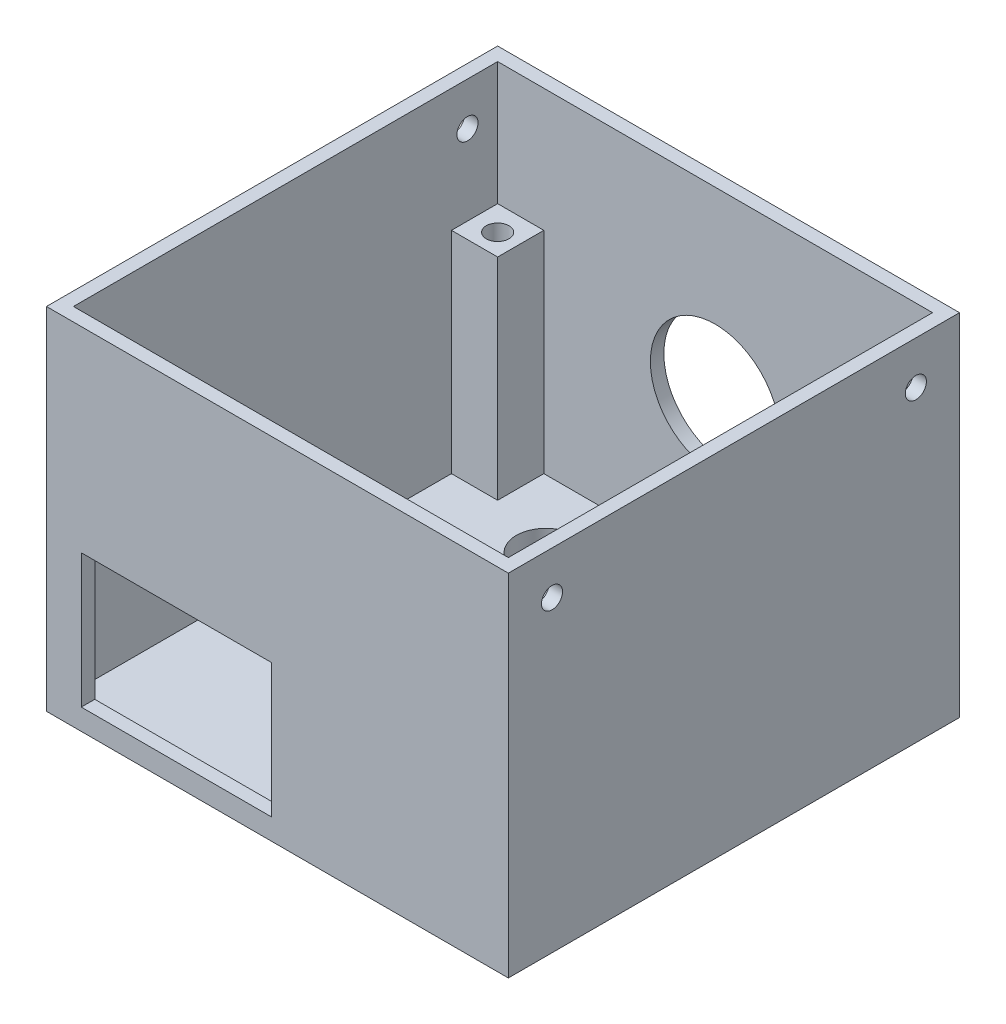
from build123d import *

# Parameters (mm, degrees)
SKETCH1_W           = 54.8
SKETCH1_H           = 53.53
BOSS_EXTRUDE1_DEPTH = 41.6
SKETCH2_W           = 51.6
SKETCH2_H           = 50.33
CUT_EXTRUDE1_DEPTH  = 39.6
SKETCH3_W           = 5.48
SKETCH3_H           = 5.48
BOSS_EXTRUDE2_DEPTH = 25
SKETCH4_R           = 1.35
CUT_EXTRUDE2_DEPTH  = 10
CUT_EXTRUDE3_REACH  = 43.6
SKETCH5_R           = 3.5
CUT_EXTRUDE4_REACH  = 43.6
SKETCH6_R           = 3.1
CUT_EXTRUDE5_REACH  = 43.6
SKETCH7_R           = 3.6
CUT_EXTRUDE6_REACH  = 56.8
SKETCH8_R           = 1.25
CUT_EXTRUDE7_REACH  = 56.8
SKETCH10_R          = 1.25
CUT_EXTRUDE8_REACH  = 55.53
SKETCH12_R          = 7.680495542
CUT_EXTRUDE9_REACH  = 55.53
SKETCH13_W          = 22.581735489
SKETCH13_H          = 15.862362247
CUT_EXTRUDE10_REACH = 56.8
SKETCH14_R          = 1.25


with BuildPart() as part:
    # Sketch1 → Boss-Extrude1 (new body)
    with BuildSketch(Plane(origin=(0, 0, 0), x_dir=(1, 0, 0), z_dir=(0, 1, 0))):
        Rectangle(SKETCH1_W, SKETCH1_H)
    extrude(amount=BOSS_EXTRUDE1_DEPTH)

    # Sketch2 → Cut-Extrude1 (cut)
    with BuildSketch(Plane(origin=(0, 41.6, 0), x_dir=(1, 0, 0), z_dir=(0, 1, 0))):
        Rectangle(SKETCH2_W, SKETCH2_H)
    extrude(amount=-CUT_EXTRUDE1_DEPTH, mode=Mode.SUBTRACT)

    # Sketch3 → Boss-Extrude2 (add)
    with BuildSketch(Plane(origin=(0, 2, 0), x_dir=(1, 0, 0), z_dir=(0, 1, 0))):
        with Locations((-23.06, 22.425)):
            Rectangle(SKETCH3_W, SKETCH3_H)
        with Locations((23.06, 22.425)):
            Rectangle(SKETCH3_W, SKETCH3_H)
        with Locations((23.06, -22.425)):
            Rectangle(SKETCH3_W, SKETCH3_H)
    extrude(amount=BOSS_EXTRUDE2_DEPTH)

    # Sketch4 → Cut-Extrude2 (cut)
    with BuildSketch(Plane(origin=(0, 27, 0), x_dir=(1, 0, 0), z_dir=(0, 1, 0))):
        with Locations((-22.86, 22.225)):
            Circle(SKETCH4_R)
        with Locations((22.86, 22.225)):
            Circle(SKETCH4_R)
        with Locations((22.86, -22.217113742)):
            Circle(SKETCH4_R)
    extrude(amount=-CUT_EXTRUDE2_DEPTH, mode=Mode.SUBTRACT)

    # Sketch5 → Cut-Extrude3 (cut, up to next)
    with BuildSketch(Plane(origin=(0, 0, 0), x_dir=(-1, 0, 0), z_dir=(0, -1, 0)), mode=Mode.PRIVATE) as cut_extrude3_sk1:
        with Locations((-12.762863618, 17.186859774)):
            Circle(SKETCH5_R)
    cut_extrude3_tool1 = extrude(cut_extrude3_sk1.sketch, amount=-CUT_EXTRUDE3_REACH, mode=Mode.PRIVATE) & part.part
    add(cut_extrude3_tool1.solids().sort_by_distance((12.762864, 0, -17.18686))[0], mode=Mode.SUBTRACT)
    # Sketch5 → Cut-Extrude3 (cut, up to next)
    with BuildSketch(Plane(origin=(0, 0, 0), x_dir=(-1, 0, 0), z_dir=(0, -1, 0)), mode=Mode.PRIVATE) as cut_extrude3_sk2:
        with Locations((12.108357792, 17.186859774)):
            Circle(SKETCH5_R)
    cut_extrude3_tool2 = extrude(cut_extrude3_sk2.sketch, amount=-CUT_EXTRUDE3_REACH, mode=Mode.PRIVATE) & part.part
    add(cut_extrude3_tool2.solids().sort_by_distance((-12.108358, 0, -17.18686))[0], mode=Mode.SUBTRACT)

    # Sketch6 → Cut-Extrude4 (cut, up to next)
    with BuildSketch(Plane(origin=(0, 0, 0), x_dir=(-1, 0, 0), z_dir=(0, -1, 0)), mode=Mode.PRIVATE) as cut_extrude4_sk1:
        with Locations((-16.908067186, 1.527180262)):
            Circle(SKETCH6_R)
    cut_extrude4_tool1 = extrude(cut_extrude4_sk1.sketch, amount=-CUT_EXTRUDE4_REACH, mode=Mode.PRIVATE) & part.part
    add(cut_extrude4_tool1.solids().sort_by_distance((16.908067, 0, -1.52718))[0], mode=Mode.SUBTRACT)
    # Sketch6 → Cut-Extrude4 (cut, up to next)
    with BuildSketch(Plane(origin=(0, 0, 0), x_dir=(-1, 0, 0), z_dir=(0, -1, 0)), mode=Mode.PRIVATE) as cut_extrude4_sk2:
        with Locations((-8.726744354, 1.527180262)):
            Circle(SKETCH6_R)
    cut_extrude4_tool2 = extrude(cut_extrude4_sk2.sketch, amount=-CUT_EXTRUDE4_REACH, mode=Mode.PRIVATE) & part.part
    add(cut_extrude4_tool2.solids().sort_by_distance((8.726744, 0, -1.52718))[0], mode=Mode.SUBTRACT)

    # Sketch7 → Cut-Extrude5 (cut, up to next)
    with BuildSketch(Plane(origin=(0, 0, 0), x_dir=(-1, 0, 0), z_dir=(0, -1, 0)), mode=Mode.PRIVATE) as cut_extrude5_sk1:
        with Locations((-12.653779314, -10.035756007)):
            Circle(SKETCH7_R)
    cut_extrude5_tool1 = extrude(cut_extrude5_sk1.sketch, amount=-CUT_EXTRUDE5_REACH, mode=Mode.PRIVATE) & part.part
    add(cut_extrude5_tool1.solids().sort_by_distance((12.653779, 0, 10.035756))[0], mode=Mode.SUBTRACT)

    # Sketch8 → Cut-Extrude6 (cut, up to next)
    with BuildSketch(Plane(origin=(27.4, 0, 0), x_dir=(0, 0, -1), z_dir=(1, 0, 0)), mode=Mode.PRIVATE) as cut_extrude6_sk1:
        with Locations((-21.585, 36.49)):
            Circle(SKETCH8_R)
    cut_extrude6_tool1 = extrude(cut_extrude6_sk1.sketch, amount=-CUT_EXTRUDE6_REACH, mode=Mode.PRIVATE) & part.part
    add(cut_extrude6_tool1.solids().sort_by_distance((27.4, 36.49, 21.585))[0], mode=Mode.SUBTRACT)

    # Sketch10 → Cut-Extrude7 (cut, up to next)
    with BuildSketch(Plane.ZY.offset(27.4), mode=Mode.PRIVATE) as cut_extrude7_sk1:
        with Locations((-21.585, 36.49)):
            Circle(SKETCH10_R)
    cut_extrude7_tool1 = extrude(cut_extrude7_sk1.sketch, amount=-CUT_EXTRUDE7_REACH, mode=Mode.PRIVATE) & part.part
    add(cut_extrude7_tool1.solids().sort_by_distance((-27.4, 36.49, -21.585))[0], mode=Mode.SUBTRACT)

    # Sketch12 → Cut-Extrude8 (cut, up to next)
    with BuildSketch(Plane(origin=(0, 0, -26.765), x_dir=(-1, 0, 0), z_dir=(0, 0, -1)), mode=Mode.PRIVATE) as cut_extrude8_sk1:
        with Locations((0, 19.850785186)):
            Circle(SKETCH12_R)
    cut_extrude8_tool1 = extrude(cut_extrude8_sk1.sketch, amount=-CUT_EXTRUDE8_REACH, mode=Mode.PRIVATE) & part.part
    add(cut_extrude8_tool1.solids().sort_by_distance((0, 19.850785, -26.765))[0], mode=Mode.SUBTRACT)

    # Sketch13 → Cut-Extrude9 (cut, up to next)
    with BuildSketch(Plane.XY.offset(26.765), mode=Mode.PRIVATE) as cut_extrude9_sk1:
        with Locations((-11.980612505, 10.431181124)):
            Rectangle(SKETCH13_W, SKETCH13_H)
    cut_extrude9_tool1 = extrude(cut_extrude9_sk1.sketch, amount=-CUT_EXTRUDE9_REACH, mode=Mode.PRIVATE) & part.part
    add(cut_extrude9_tool1.solids().sort_by_distance((-11.980613, 10.431181, 26.765))[0], mode=Mode.SUBTRACT)

    # Sketch14 → Cut-Extrude10 (cut, up to next)
    with BuildSketch(Plane(origin=(27.4, 0, 0), x_dir=(0, 0, -1), z_dir=(1, 0, 0)), mode=Mode.PRIVATE) as cut_extrude10_sk1:
        with Locations((21.585, 36.49)):
            Circle(SKETCH14_R)
    cut_extrude10_tool1 = extrude(cut_extrude10_sk1.sketch, amount=-CUT_EXTRUDE10_REACH, mode=Mode.PRIVATE) & part.part
    add(cut_extrude10_tool1.solids().sort_by_distance((27.4, 36.49, -21.585))[0], mode=Mode.SUBTRACT)


solid = part.part
